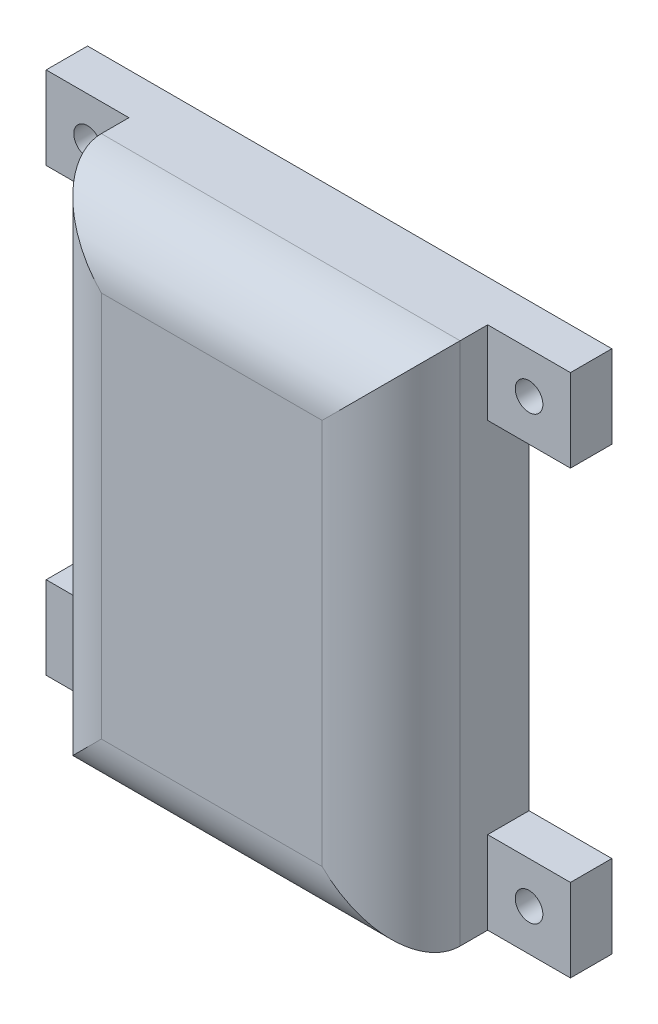
from build123d import *

# Parameters (mm, degrees)
SKETCH_1_W          = 26
SKETCH_1_H          = 38
EXTRUDE_1_DEPTH     = 10
SKETCH_2_W          = 22
SKETCH_2_H          = 34
CUT_EXTRUDE_1_DEPTH = 8
SKETCH_4_W          = 6
SKETCH_4_H          = 6
EXTRUDE_2_DEPTH     = 3
SKETCH_5_R          = 1
CUT_EXTRUDE_4_DEPTH = 11
FILLET_1_R          = 5


with BuildPart() as part:
    # ｽｹｯﾁ1 → ﾎﾞｽ - 押し出し1 (new body)
    with BuildSketch(Plane.XY):
        Rectangle(SKETCH_1_W, SKETCH_1_H)
    extrude(amount=EXTRUDE_1_DEPTH)

    # ｽｹｯﾁ2 → ｶｯﾄ - 押し出し1 (cut)
    with BuildSketch(Plane.XY):
        Rectangle(SKETCH_2_W, SKETCH_2_H)
    extrude(amount=CUT_EXTRUDE_1_DEPTH, mode=Mode.SUBTRACT)

    # ｽｹｯﾁ4 → ﾎﾞｽ - 押し出し2 (add)
    with BuildSketch(Plane.XY):
        with Locations((16, 16)):
            Rectangle(SKETCH_4_W, SKETCH_4_H)
        with Locations((16, -16)):
            Rectangle(SKETCH_4_W, SKETCH_4_H)
        with Locations((-16, -16)):
            Rectangle(SKETCH_4_W, SKETCH_4_H)
        with Locations((-16, 16)):
            Rectangle(SKETCH_4_W, SKETCH_4_H)
    extrude(amount=EXTRUDE_2_DEPTH)

    # ｽｹｯﾁ5 → ｶｯﾄ - 押し出し4 (cut, through all)
    with BuildSketch(Plane.XY):
        with Locations((-16, 16)):
            Circle(SKETCH_5_R)
        with Locations((-16, -16)):
            Circle(SKETCH_5_R)
        with Locations((16, -16)):
            Circle(SKETCH_5_R)
        with Locations((16, 16)):
            Circle(SKETCH_5_R)
    extrude(amount=CUT_EXTRUDE_4_DEPTH, mode=Mode.SUBTRACT)

    # ﾌｨﾚｯﾄ1
    fillet_1_edges = [part.edges().sort_by_distance(p)[0] for p in [
        (0, 19, 10),
        (0, -19, 10),
        (13, 0, 10),
        (-13, 0, 10),
    ]]
    fillet(fillet_1_edges, radius=FILLET_1_R)


solid = part.part
